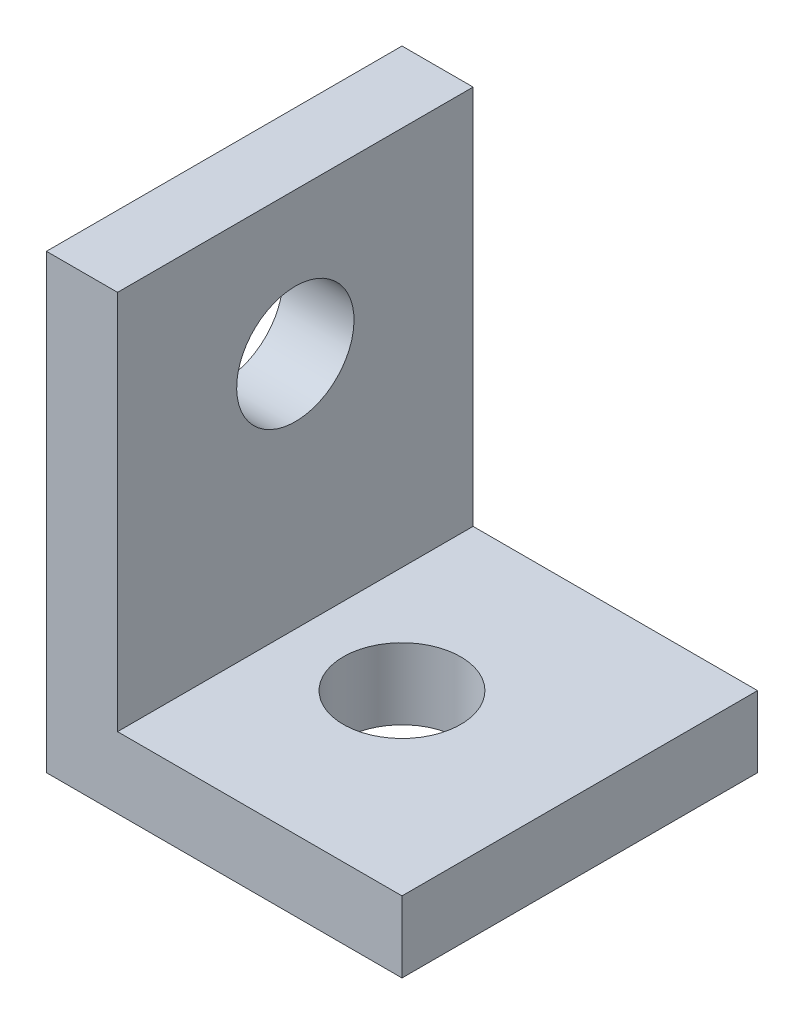
from build123d import *

# Parameters (mm, degrees)
BOSS_EXTRUDE1_DEPTH = 5
SKETCH2_R           = 1.65
CUT_EXTRUDE1_DEPTH  = 3
SKETCH3_R           = 1.65
CUT_EXTRUDE2_DEPTH  = 10


with BuildPart() as part:
    # Sketch1 → Boss-Extrude1 (new body, symmetric)
    with BuildSketch(Plane.XY):
        Polygon((-5, 6.35), (-5, -6.35), (5, -6.35), (5, -4.35), (-3, -4.35), (-3, 6.35), align=None)
    extrude(amount=BOSS_EXTRUDE1_DEPTH, both=True)

    # Sketch2 → Cut-Extrude1 (cut, through all)
    with BuildSketch(Plane(origin=(0, -4.35, 0), x_dir=(1, 0, 0), z_dir=(0, 1, 0))):
        Circle(SKETCH2_R)
    extrude(amount=-CUT_EXTRUDE1_DEPTH, mode=Mode.SUBTRACT)

    # Sketch3 → Cut-Extrude2 (cut)
    with BuildSketch(Plane(origin=(-3, 0, 0), x_dir=(0, 0, -1), z_dir=(1, 0, 0))):
        with Locations((0, 2.35)):
            Circle(SKETCH3_R)
    extrude(amount=-CUT_EXTRUDE2_DEPTH, mode=Mode.SUBTRACT)


solid = part.part
